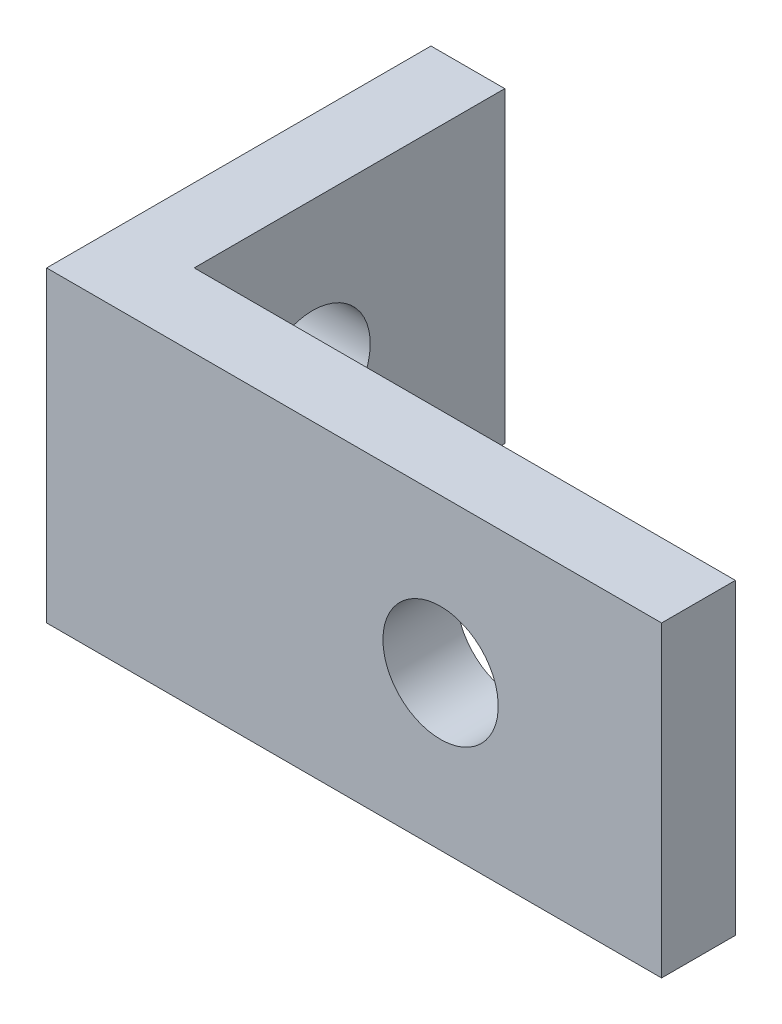
from build123d import *

# Parameters (mm, degrees)
SKETCH1_W           = 25.4
SKETCH1_H           = 12.7
BOSS_EXTRUDE1_DEPTH = 3.048
SKETCH2_W           = 3.048
SKETCH2_H           = 12.7
BOSS_EXTRUDE2_DEPTH = 15.875
SKETCH3_R           = 2.38125
CUT_EXTRUDE1_DEPTH  = 4.048
SKETCH4_R           = 2.38125
CUT_EXTRUDE2_DEPTH  = 4.048


with BuildPart() as part:
    # Sketch1 → Boss-Extrude1 (new body)
    with BuildSketch(Plane.XY):
        with Locations((12.7, 6.35)):
            Rectangle(SKETCH1_W, SKETCH1_H)
    extrude(amount=BOSS_EXTRUDE1_DEPTH)

    # Sketch2 → Boss-Extrude2 (add)
    with BuildSketch(Plane.XY.offset(3.048)):
        with Locations((1.524, 6.35)):
            Rectangle(SKETCH2_W, SKETCH2_H)
    extrude(amount=-BOSS_EXTRUDE2_DEPTH)

    # Sketch3 → Cut-Extrude1 (cut, through all)
    with BuildSketch(Plane(origin=(0, 0, 0), x_dir=(-1, 0, 0), z_dir=(0, 0, -1))):
        with Locations((-16.271875, 6.35)):
            Circle(SKETCH3_R)
    extrude(amount=-CUT_EXTRUDE1_DEPTH, mode=Mode.SUBTRACT)

    # Sketch4 → Cut-Extrude2 (cut, through all)
    with BuildSketch(Plane(origin=(3.048, 0, 0), x_dir=(0, 0, -1), z_dir=(1, 0, 0))):
        with Locations((4.8895, 6.35)):
            Circle(SKETCH4_R)
    extrude(amount=-CUT_EXTRUDE2_DEPTH, mode=Mode.SUBTRACT)


solid = part.part
